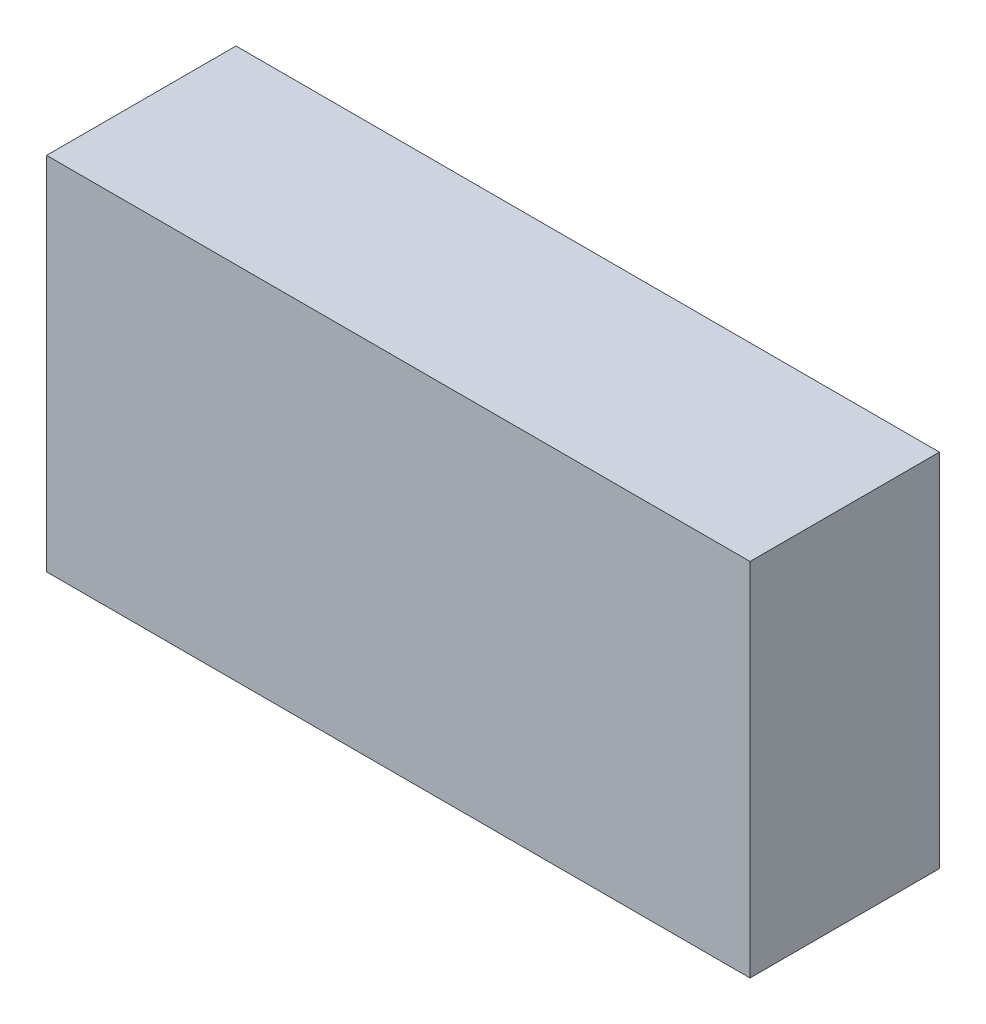
from build123d import *

# Parameters (mm, degrees)
SKETCH_1_W      = 78
SKETCH_1_H      = 40
EXTRUDE_1_DEPTH = 21


with BuildPart() as part:
    # 草图1 → 凸台-拉伸1 (new body)
    with BuildSketch(Plane.XY):
        Rectangle(SKETCH_1_W, SKETCH_1_H)
    extrude(amount=EXTRUDE_1_DEPTH)


solid = part.part
